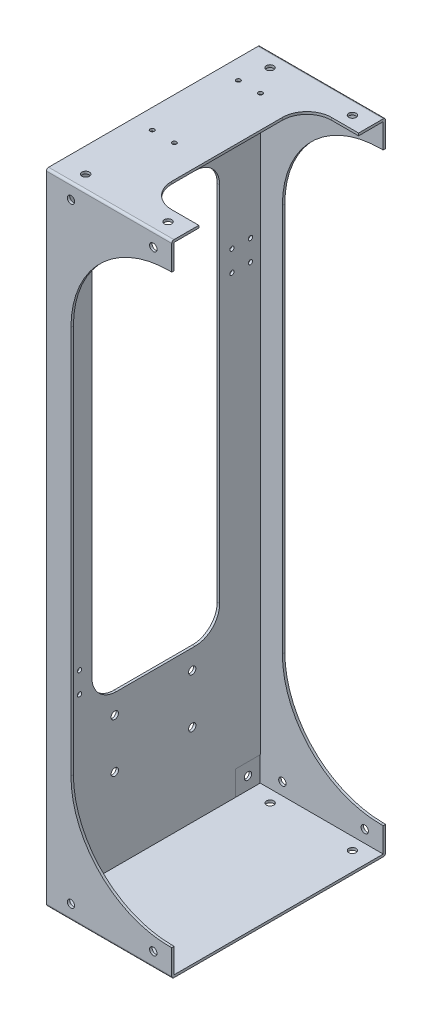
from build123d import *

# Parameters (mm, degrees)
SKETCH1_W           = 174
SKETCH1_H           = 520
BOSS_EXTRUDE1_DEPTH = 2
SKETCH2_W           = 174
SKETCH2_H           = 520
SKETCH2_W_2         = 170
SKETCH2_H_2         = 516
BOSS_EXTRUDE2_DEPTH = 100
CUT_EXTRUDE1_DEPTH  = 10
SKETCH4_R           = 3
CUT_EXTRUDE2_DEPTH  = 175
SKETCH5_R           = 3
CUT_EXTRUDE3_DEPTH  = 521
CUT_EXTRUDE4_DEPTH  = 10
SKETCH8_R           = 1.75
CUT_EXTRUDE5_DEPTH  = 10
FILLET1_R           = 1.8
SKETCH9_R           = 3
CUT_EXTRUDE6_DEPTH  = 10
SKETCH10_R          = 3
SKETCH10_R_2        = 1.75
CUT_EXTRUDE7_DEPTH  = 103
SKETCH11_W          = 20
SKETCH11_H          = 20
CUT_EXTRUDE8_DEPTH  = 0.01


with BuildPart() as part:
    # Sketch1 → Boss-Extrude1 (new body)
    with BuildSketch(Plane(origin=(0, 0, 0), x_dir=(0, 0, -1), z_dir=(1, 0, 0))):
        Rectangle(SKETCH1_W, SKETCH1_H)
    extrude(amount=BOSS_EXTRUDE1_DEPTH)

    # Sketch2 → Boss-Extrude2 (add)
    with BuildSketch(Plane(origin=(2, 0, 0), x_dir=(0, 0, -1), z_dir=(1, 0, 0))):
        Rectangle(SKETCH2_W, SKETCH2_H)
        Rectangle(SKETCH2_W_2, SKETCH2_H_2, mode=Mode.SUBTRACT)
    extrude(amount=BOSS_EXTRUDE2_DEPTH)

    # Sketch3 → Cut-Extrude1 (cut)
    with BuildSketch(Plane.XY.offset(-87)):
        with BuildLine():
            Line((102, 238), (100, 238))
            ThreePointArc((100, 238), (43.431457505, 214.568542495), (20, 158))
            Line((20, 158), (20, -158))
            ThreePointArc((20, -158), (43.431457505, -214.568542495), (100, -238))
            Line((100, -238), (102, -238))
            Line((102, -238), (102, 238))
        make_face()
    extrude(amount=CUT_EXTRUDE1_DEPTH, mode=Mode.SUBTRACT)

    # Sketch4 → Cut-Extrude2 (cut, through all)
    with BuildSketch(Plane.XY.offset(87)):
        with Locations((20, 248)):
            Circle(SKETCH4_R)
        with Locations((87, 248)):
            Circle(SKETCH4_R)
        with Locations((20, -248)):
            Circle(SKETCH4_R)
        with Locations((87, -248)):
            Circle(SKETCH4_R)
    extrude(amount=-CUT_EXTRUDE2_DEPTH, mode=Mode.SUBTRACT)

    # Sketch5 → Cut-Extrude3 (cut, through all)
    with BuildSketch(Plane(origin=(0, 260, 0), x_dir=(1, 0, 0), z_dir=(0, 1, 0))):
        with Locations(Location((87, 75, 0), (0, 0, 270))):  # turned: the seam where the file's is
            Circle(SKETCH5_R)
        with Locations(Location((20, 75, 0), (0, 0, 270))):  # turned: the seam where the file's is
            Circle(SKETCH5_R)
        with Locations(Location((87, -75, 0), (0, 0, 270))):  # turned: the seam where the file's is
            Circle(SKETCH5_R)
        with Locations(Location((20, -75, 0), (0, 0, 270))):  # turned: the seam where the file's is
            Circle(SKETCH5_R)
    extrude(amount=-CUT_EXTRUDE3_DEPTH, mode=Mode.SUBTRACT)

    # Sketch7 → Cut-Extrude4 (cut)
    with BuildSketch(Plane(origin=(0, 0, 87), x_dir=(-1, 0, 0), z_dir=(0, 0, -1))):
        with BuildLine():
            Line((-102, 238), (-100, 238))
            ThreePointArc((-100, 238), (-43.431457505, 214.568542495), (-20, 158))
            Line((-20, 158), (-20, -158))
            ThreePointArc((-20, -158), (-43.431457505, -214.568542495), (-100, -238))
            Line((-100, -238), (-102, -238))
            Line((-102, -238), (-102, 238))
        make_face()
    extrude(amount=CUT_EXTRUDE4_DEPTH, mode=Mode.SUBTRACT)

    # Sketch8 → Cut-Extrude5 (cut)
    with BuildSketch(Plane(origin=(0, 260, 0), x_dir=(1, 0, 0), z_dir=(0, 1, 0))):
        with Locations(Location((34, 53.15, 0), (0, 0, 270))):  # turned: the seam where the file's is
            Circle(SKETCH8_R)
        with Locations(Location((16, 53.15, 0), (0, 0, 270))):  # turned: the seam where the file's is
            Circle(SKETCH8_R)
        with Locations(Location((16, -16.85, 0), (0, 0, 270))):  # turned: the seam where the file's is
            Circle(SKETCH8_R)
        with Locations(Location((34, -16.85, 0), (0, 0, 270))):  # turned: the seam where the file's is
            Circle(SKETCH8_R)
        with BuildLine():
            Line((102, 65), (80, 65))
            ThreePointArc((80, 65), (65.857864376, 59.142135624), (60, 45))
            Line((60, 45), (60, -45))
            ThreePointArc((60, -45), (65.857864376, -59.142135624), (80, -65))
            Line((80, -65), (102, -65))
            Line((102, -65), (102, 65))
        make_face()
    extrude(amount=-CUT_EXTRUDE5_DEPTH, mode=Mode.SUBTRACT)

    # Fillet1
    fillet1_edges = [part.edges().sort_by_distance(p)[0] for p in [
        (51, 260, 87),
        (51, 260, -87),
        (51, -260, -87),
        (51, -260, 87),
    ]]
    fillet(fillet1_edges, radius=FILLET1_R)

    # Sketch9 → Cut-Extrude6 (cut)
    with BuildSketch(Plane.ZY):
        with Locations((-75, 248)):
            Circle(SKETCH9_R)
        with Locations((75, 248)):
            Circle(SKETCH9_R)
        with Locations((75, -248)):
            Circle(SKETCH9_R)
        with Locations((-75, -248)):
            Circle(SKETCH9_R)
    extrude(amount=-CUT_EXTRUDE6_DEPTH, mode=Mode.SUBTRACT)

    # Sketch10 → Cut-Extrude7 (cut, through all)
    with BuildSketch(Plane.ZY):
        with Locations((-29.65, -151)):
            Circle(SKETCH10_R)
        with Locations((33.35, -151)):
            Circle(SKETCH10_R)
        with Locations((-29.65, -191)):
            Circle(SKETCH10_R)
        with Locations((33.35, -191)):
            Circle(SKETCH10_R)
        with Locations((62, 233)):
            Circle(SKETCH10_R_2)
        with Locations((77, 233)):
            Circle(SKETCH10_R_2)
        with Locations((62, 216)):
            Circle(SKETCH10_R_2)
        with Locations((77, 216)):
            Circle(SKETCH10_R_2)
        with Locations((-77, 130)):
            Circle(SKETCH10_R_2)
        with Locations((-62, 130)):
            Circle(SKETCH10_R_2)
        with Locations((-62, 113)):
            Circle(SKETCH10_R_2)
        with Locations((-77, 113)):
            Circle(SKETCH10_R_2)
        with Locations((62, -105)):
            Circle(SKETCH10_R_2)
        with Locations((77, -105)):
            Circle(SKETCH10_R_2)
        with Locations((62, -122)):
            Circle(SKETCH10_R_2)
        with Locations((77, -122)):
            Circle(SKETCH10_R_2)
        with BuildLine():
            Line((-32, 200), (32, 200))
            ThreePointArc((32, 200), (46.142135624, 194.142135624), (52, 180))
            Line((52, 180), (52, -115))
            ThreePointArc((52, -115), (46.142135624, -129.142135624), (32, -135))
            Line((32, -135), (-32, -135))
            ThreePointArc((-32, -135), (-46.142135624, -129.142135624), (-52, -115))
            Line((-52, -115), (-52, 180))
            ThreePointArc((-52, 180), (-46.142135624, 194.142135624), (-32, 200))
        make_face()
    extrude(amount=-CUT_EXTRUDE7_DEPTH, mode=Mode.SUBTRACT)

    # Sketch11 → Cut-Extrude8 (cut)
    with BuildSketch(Plane(origin=(2, 0, 0), x_dir=(0, 0, -1), z_dir=(1, 0, 0))):
        with Locations((-75, 248)):
            Rectangle(SKETCH11_W, SKETCH11_H)
        with Locations((75, 248)):
            Rectangle(SKETCH11_W, SKETCH11_H)
        with Locations((75, -248)):
            Rectangle(SKETCH11_W, SKETCH11_H)
        with Locations((-75, -248)):
            Rectangle(SKETCH11_W, SKETCH11_H)
    extrude(amount=-CUT_EXTRUDE8_DEPTH, mode=Mode.SUBTRACT)


solid = part.part
